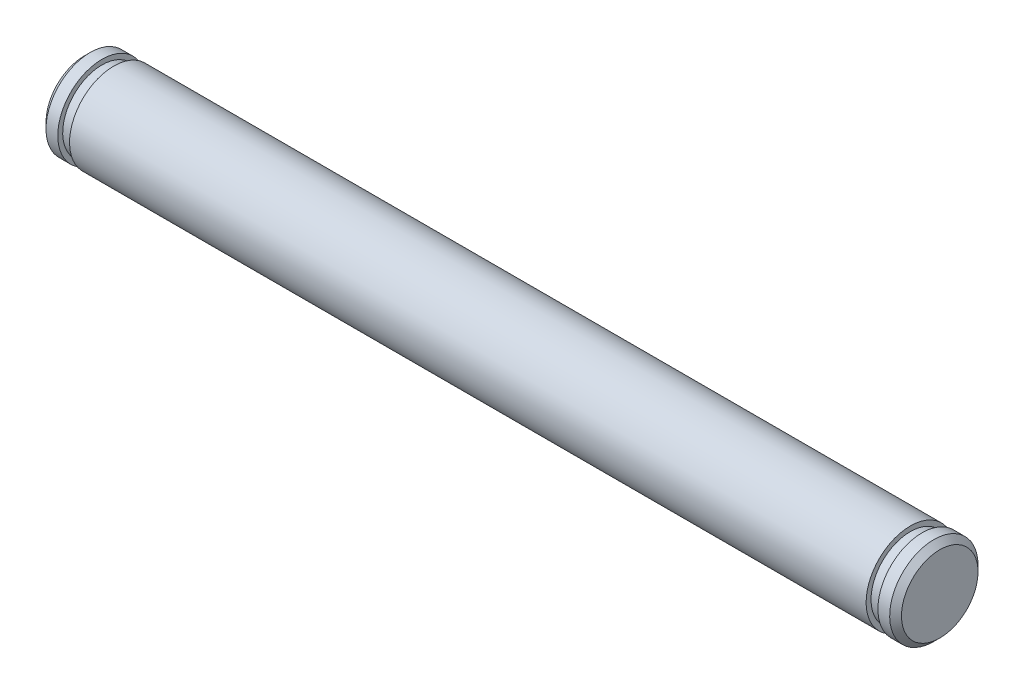
from build123d import *

# Parameters (mm, degrees)
CHAMFER1_SIZE = 0.4


with BuildPart() as part:
    # Sketch1 → Revolve1 (revolve)
    with BuildSketch(Plane.XY):
        Polygon((-2, 0), (56.102, 0), (56.102, 3), (54.902, 3), (54.902, 2.667), (54.102, 2.667), (54.102, 3), (0, 3), (0, 2.667), (-0.8, 2.667), (-0.8, 3), (-2, 3), align=None)
    revolve(axis=Axis((-2, 0, 0), (-1, 0, 0)))

    # Chamfer1
    chamfer1_edges = [part.edges().sort_by_distance(p)[0] for p in [
        (-2, -3, 0),
        (56.102, -3, 0),
    ]]
    chamfer(chamfer1_edges, length=CHAMFER1_SIZE)


solid = part.part
